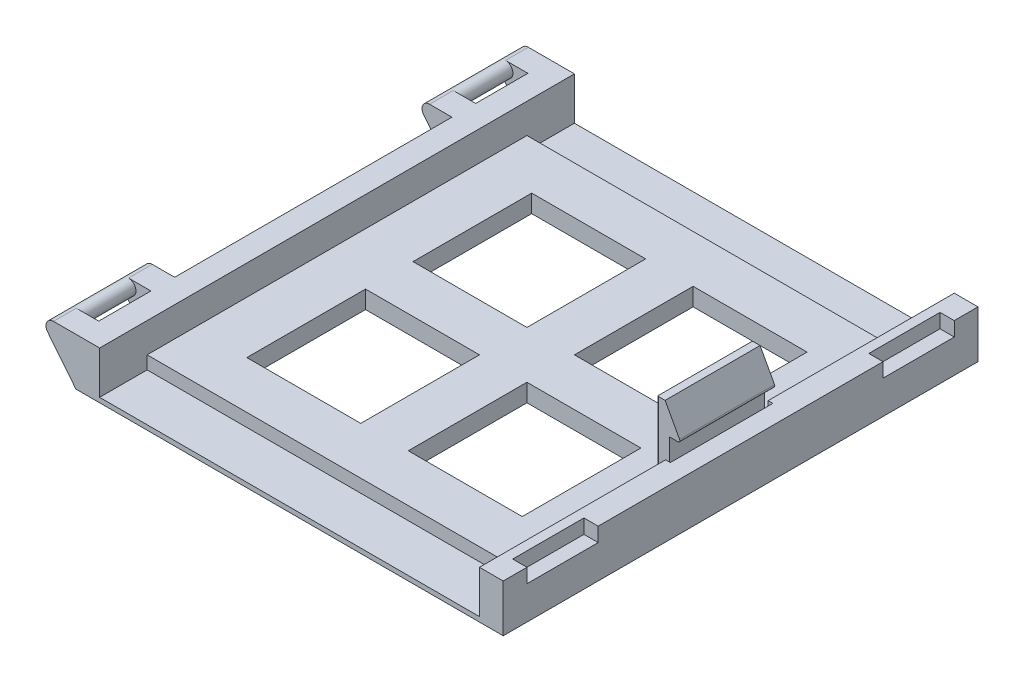
from build123d import *

# Parameters (mm, degrees)
BOSS_EXTRUDE1_DEPTH     = 31.75
BOSS_EXTRUDE2_DEPTH     = 6.35
CUT_EXTRUDE2_DEPTH      = 6.4135
BOSS_EXTRUDE3_START     = 28.702
BOSS_EXTRUDE3_DEPTH     = 3.048
BOSS_EXTRUDE5_START     = -31.75
BOSS_EXTRUDE5_DEPTH     = 3.048
BOSS_EXTRUDE7_START     = 21.717
BOSS_EXTRUDE7_DEPTH     = 3.175
BOSS_EXTRUDE8_START     = -21.717
BOSS_EXTRUDE8_DEPTH     = 3.175
BOSS_EXTRUDE6_START     = 31.75
BOSS_EXTRUDE6_DEPTH     = 13.208
BOSS_EXTRUDE9_START     = -31.75
BOSS_EXTRUDE9_DEPTH     = 13.208
SKETCH3_W               = 15.24
SKETCH3_H               = 15.875
CUT_EXTRUDE4_DEPTH      = 11.31875
CUT_EXTRUDE4_DEPTH_BACK = 3.38125
SKETCH5_W               = 50.8
SKETCH5_H               = 1.74625
CUT_EXTRUDE6_DEPTH      = 6.35
SKETCH6_W               = 9.525
SKETCH6_H               = 1.905
CUT_EXTRUDE7_DEPTH      = 1.905


with BuildPart() as part:
    # Sketch1 → Boss-Extrude1 (new body, symmetric)
    with BuildSketch(Plane.XY):
        Polygon((-25.4, -0.79375), (-25.4, 3.175), (-28.575, 3.175), (-28.575, -3.175), (28.575, -3.175), (28.575, 3.175), (25.4, 3.175), (25.4, -0.79375), align=None)
    extrude(amount=BOSS_EXTRUDE1_DEPTH, both=True)

    # Sketch1_3 → Boss-Extrude2 (add, symmetric)
    with BuildSketch(Plane.XY):
        with BuildLine():
            Line((23.8125, 9.525), (23.8125, -0.79375))
            Line((23.8125, -0.79375), (25.4, -0.79375))
            Line((25.4, -0.79375), (25.4, 5.588))
            Line((25.4, 5.588), (26.543, 5.588))
            ThreePointArc((26.543, 5.588), (26.761343, 5.712222), (26.766119, 5.963383))
            Line((26.766119, 5.963383), (24.8285, 9.525))
            Line((24.8285, 9.525), (23.8125, 9.525))
        make_face()
    extrude(amount=BOSS_EXTRUDE2_DEPTH, both=True)

    # Sketch1_6 → Cut-Extrude2 (cut, symmetric)
    with BuildSketch(Plane.XY):
        with BuildLine():
            Line((26.035, 3.175), (25.4, 3.175))
            Line((25.4, 3.175), (25.4, -0.79375))
            Line((25.4, -0.79375), (25.4, -2.06375))
            ThreePointArc((25.4, -2.06375), (25.7175, -2.38125), (26.035, -2.06375))
            Line((26.035, -2.06375), (26.035, 3.175))
        make_face()
    extrude(amount=CUT_EXTRUDE2_DEPTH, both=True, mode=Mode.SUBTRACT)

    # Cut-Sweep1: sweep along a path in Sketch7
    with BuildLine(Plane(origin=(0, -0.79375, 0), x_dir=(1, 0, 0), z_dir=(0, 1, 0))) as cut_sweep1_path:
        Line((26.035, 6.35), (23.9395, 6.35))
        ThreePointArc((23.9395, 6.35), (23.849697, 6.312803), (23.8125, 6.223))
        Line((23.8125, 6.223), (23.8125, -6.223))
        ThreePointArc((23.8125, -6.223), (23.849697, -6.312803), (23.9395, -6.35))
        Line((23.9395, -6.35), (26.035, -6.35))
    # Sketch8 → Cut-Sweep1 (sweep, cut)
    with BuildSketch(Plane(origin=(26.035, 0, 0), x_dir=(0, 0, -1), z_dir=(1, 0, 0))):
        with BuildLine():
            Line((-6.858, -2.69875), (-6.858, 9.525))
            Line((-6.858, 9.525), (-6.35, 9.525))
            Line((-6.35, 9.525), (-6.35, -2.69875))
            ThreePointArc((-6.35, -2.69875), (-6.604, -2.95275), (-6.858, -2.69875))
        make_face()
    sweep(path=cut_sweep1_path.line, mode=Mode.SUBTRACT)

    # Sketch1_7 → Boss-Extrude3 (add)
    with BuildSketch(Plane.XY.offset(BOSS_EXTRUDE3_START)):
        with BuildLine():
            ThreePointArc((-32.355812, 1.550246), (-32.476313, 2.608154), (-31.574994, 3.175))
            Line((-31.574994, 3.175), (-28.575, 3.175))
            Line((-28.575, 3.175), (-28.575, -3.175))
            Line((-28.575, -3.175), (-32.355812, 1.550246))
        make_face()
        with BuildLine():
            ThreePointArc((-30.574996, 2.175002), (-30.867889, 2.882107), (-31.574994, 3.175))
            ThreePointArc((-31.574994, 3.175), (-32.476313, 2.608154), (-32.355812, 1.550246))
            ThreePointArc((-32.355812, 1.550246), (-31.24395, 1.231389), (-30.574996, 2.175002))
        make_face()
    extrude(amount=BOSS_EXTRUDE3_DEPTH)

    # Sketch1_9 → Boss-Extrude5 (add)
    with BuildSketch(Plane.XY.offset(BOSS_EXTRUDE5_START)):
        with BuildLine():
            ThreePointArc((-32.355812, 1.550246), (-32.476313, 2.608154), (-31.574994, 3.175))
            Line((-31.574994, 3.175), (-28.575, 3.175))
            Line((-28.575, 3.175), (-28.575, -3.175))
            Line((-28.575, -3.175), (-32.355812, 1.550246))
        make_face()
        with BuildLine():
            ThreePointArc((-30.574996, 2.175002), (-30.867889, 2.882107), (-31.574994, 3.175))
            ThreePointArc((-31.574994, 3.175), (-32.476313, 2.608154), (-32.355812, 1.550246))
            ThreePointArc((-32.355812, 1.550246), (-31.24395, 1.231389), (-30.574996, 2.175002))
        make_face()
    extrude(amount=BOSS_EXTRUDE5_DEPTH)

    # Sketch1_13 → Boss-Extrude7 (add)
    with BuildSketch(Plane.XY.offset(BOSS_EXTRUDE7_START)):
        with BuildLine():
            Line((-28.575, -3.175), (-28.575, 3.175))
            Line((-28.575, 3.175), (-31.574994, 3.175))
            ThreePointArc((-31.574994, 3.175), (-30.867889, 2.882107), (-30.574996, 2.175002))
            ThreePointArc((-30.574996, 2.175002), (-31.24395, 1.231389), (-32.355812, 1.550246))
            Line((-32.355812, 1.550246), (-28.575, -3.175))
        make_face()
        with BuildLine():
            ThreePointArc((-30.574996, 2.175002), (-30.867889, 2.882107), (-31.574994, 3.175))
            ThreePointArc((-31.574994, 3.175), (-32.476313, 2.608154), (-32.355812, 1.550246))
            ThreePointArc((-32.355812, 1.550246), (-31.24395, 1.231389), (-30.574996, 2.175002))
        make_face()
    extrude(amount=-BOSS_EXTRUDE7_DEPTH)

    # Sketch1_14 → Boss-Extrude8 (add)
    with BuildSketch(Plane.XY.offset(BOSS_EXTRUDE8_START)):
        with BuildLine():
            Line((-28.575, -3.175), (-28.575, 3.175))
            Line((-28.575, 3.175), (-31.574994, 3.175))
            ThreePointArc((-31.574994, 3.175), (-30.867889, 2.882107), (-30.574996, 2.175002))
            ThreePointArc((-30.574996, 2.175002), (-31.24395, 1.231389), (-32.355812, 1.550246))
            Line((-32.355812, 1.550246), (-28.575, -3.175))
        make_face()
        with BuildLine():
            ThreePointArc((-30.574996, 2.175002), (-30.867889, 2.882107), (-31.574994, 3.175))
            ThreePointArc((-31.574994, 3.175), (-32.476313, 2.608154), (-32.355812, 1.550246))
            ThreePointArc((-32.355812, 1.550246), (-31.24395, 1.231389), (-30.574996, 2.175002))
        make_face()
    extrude(amount=BOSS_EXTRUDE8_DEPTH)

    # Sketch1_10 → Boss-Extrude6 (add)
    with BuildSketch(Plane.XY.offset(BOSS_EXTRUDE6_START)):
        with BuildLine():
            ThreePointArc((-30.574996, 2.175002), (-30.867889, 2.882107), (-31.574994, 3.175))
            ThreePointArc((-31.574994, 3.175), (-32.476313, 2.608154), (-32.355812, 1.550246))
            ThreePointArc((-32.355812, 1.550246), (-31.24395, 1.231389), (-30.574996, 2.175002))
        make_face()
    extrude(amount=-BOSS_EXTRUDE6_DEPTH)

    # Sketch1_16 → Boss-Extrude9 (add)
    with BuildSketch(Plane.XY.offset(BOSS_EXTRUDE9_START)):
        with BuildLine():
            ThreePointArc((-30.574996, 2.175002), (-30.867889, 2.882107), (-31.574994, 3.175))
            ThreePointArc((-31.574994, 3.175), (-32.476313, 2.608154), (-32.355812, 1.550246))
            ThreePointArc((-32.355812, 1.550246), (-31.24395, 1.231389), (-30.574996, 2.175002))
        make_face()
    extrude(amount=BOSS_EXTRUDE9_DEPTH)

    # Sketch3 → Cut-Extrude4 (cut, two sides)
    with BuildSketch(Plane(origin=(0, -0.79375, 0), x_dir=(1, 0, 0), z_dir=(0, 1, 0))) as cut_extrude4_sk:
        with Locations((10.795, 11.1125)):
            Rectangle(SKETCH3_W, SKETCH3_H)
        with Locations((-10.795, 11.1125)):
            Rectangle(SKETCH3_W, SKETCH3_H)
        with Locations((10.795, -11.1125)):
            Rectangle(SKETCH3_W, SKETCH3_H)
        with Locations((-10.795, -11.1125)):
            Rectangle(SKETCH3_W, SKETCH3_H)
    extrude(amount=CUT_EXTRUDE4_DEPTH, mode=Mode.SUBTRACT)
    extrude(cut_extrude4_sk.sketch, amount=-CUT_EXTRUDE4_DEPTH_BACK, mode=Mode.SUBTRACT)

    # Sketch5 → Cut-Extrude6 (cut)
    with BuildSketch(Plane.XY.offset(31.75)):
        with Locations((0, -1.666875)):
            Rectangle(SKETCH5_W, SKETCH5_H)
    cut_extrude6 = extrude(amount=-CUT_EXTRUDE6_DEPTH, mode=Mode.SUBTRACT)

    # Mirror1: Cut-Extrude6 across plane
    add(cut_extrude6.mirror(Plane.XY), mode=Mode.SUBTRACT)

    # Sketch6 → Cut-Extrude7 (cut)
    with BuildSketch(Plane(origin=(28.575, 0, 0), x_dir=(0, 0, -1), z_dir=(1, 0, 0))):
        with Locations((-23.8125, 2.2225)):
            Rectangle(SKETCH6_W, SKETCH6_H)
        with Locations((23.8125, 2.2225)):
            Rectangle(SKETCH6_W, SKETCH6_H)
    extrude(amount=-CUT_EXTRUDE7_DEPTH, mode=Mode.SUBTRACT)


solid = part.part
